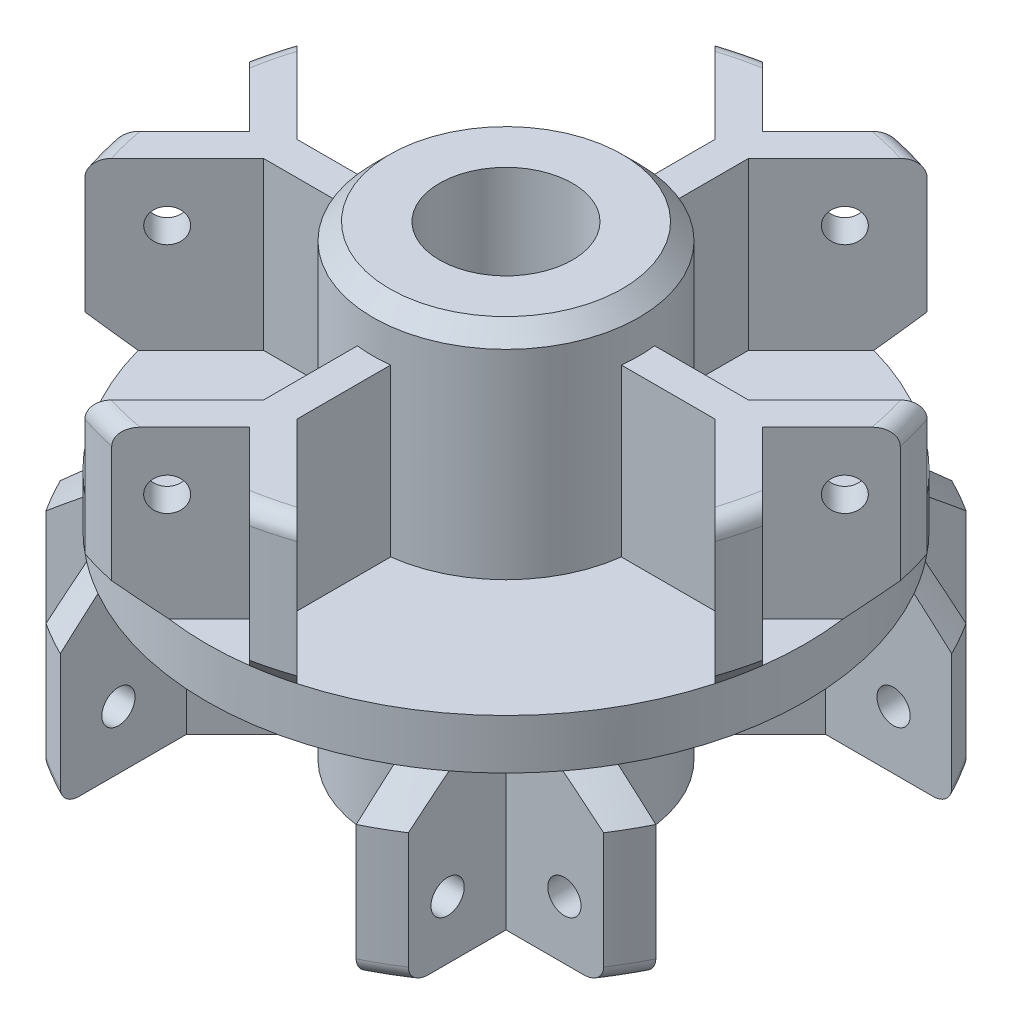
from build123d import *

# Parameters (mm, degrees)
SCHIZZO2_R                   = 20
ESTRUSIONE_ESTRUSIONE1_DEPTH = 14.5
SCHIZZO3_OUTSIDE_W           = 54.714
SCHIZZO3_OUTSIDE_H           = 54.714
SCHIZZO3_OUTSIDE_R           = 8
TAGLIO_ESTRUSIONE1_DEPTH     = 13
ESTRUSIONE_ESTRUSIONE2_DEPTH = 10
ESTRUSIONE_ESTRUSIONE3_DEPTH = 10
SMUSSO1_SIZE                 = 1
RACCORDO1_R                  = 1
SCHIZZO11_R                  = 4
TAGLIO_ESTRUSIONE2_DEPTH     = 30
FORO_2_0_2_1_D               = 2
RIPETIZIONECIRCOLARE1_COUNT  = 4
RIPETIZIONECIRCOLARE2_COUNT  = 4


with BuildPart() as part:
    # Schizzo2 → Estrusione-Estrusione1 (new body, symmetric)
    with BuildSketch(Plane(origin=(0, 0, 0), x_dir=(1, 0, 0), z_dir=(0, 1, 0))):
        Circle(SCHIZZO2_R)
    extrude(amount=ESTRUSIONE_ESTRUSIONE1_DEPTH, both=True)

    # Schizzo3 outside → Taglio-Estrusione1 (cut)
    with BuildSketch(Plane(origin=(0, 14.5, 0), x_dir=(1, 0, 0), z_dir=(0, 1, 0))):
        Rectangle(SCHIZZO3_OUTSIDE_W, SCHIZZO3_OUTSIDE_H)
        Circle(SCHIZZO3_OUTSIDE_R, mode=Mode.SUBTRACT)
    taglio_estrusione1 = extrude(amount=-TAGLIO_ESTRUSIONE1_DEPTH, mode=Mode.SUBTRACT)

    # Specchia2: Taglio-Estrusione1 across plane
    add(taglio_estrusione1.mirror(Plane.ZX), mode=Mode.SUBTRACT)

    # Schizzo6 → Estrusione-Estrusione2 (add)
    with BuildSketch(Plane(origin=(0, 1.5, 0), x_dir=(1, 0, 0), z_dir=(0, 1, 0))):
        with BuildLine():
            Line((1, 7.937253933), (1, 13.585786438))
            Line((1, 13.585786438), (6.371999001, 18.957785439))
            ThreePointArc((6.371999001, 18.957785439), (5.269942048, 19.293203747), (4.150401602, 19.564615165))
            Line((4.150401602, 19.564615165), (0, 15.414213562))
            Line((0, 15.414213562), (-4.150401602, 19.564615165))
            ThreePointArc((-4.150401602, 19.564615165), (-5.269942048, 19.293203747), (-6.371999001, 18.957785439))
            Line((-6.371999001, 18.957785439), (-1, 13.585786438))
            Line((-1, 13.585786438), (-1, 7.937253933))
            ThreePointArc((-1, 7.937253933), (0, 8), (1, 7.937253933))
        make_face()
        with BuildLine():
            Line((13.585786438, 1), (18.957785439, 6.371999001))
            ThreePointArc((18.957785439, 6.371999001), (19.293203747, 5.269942048), (19.564615165, 4.150401602))
            Line((19.564615165, 4.150401602), (15.414213562, 0))
            Line((15.414213562, 0), (19.564615165, -4.150401602))
            ThreePointArc((19.564615165, -4.150401602), (19.293203747, -5.269942048), (18.957785439, -6.371999001))
            Line((18.957785439, -6.371999001), (13.585786438, -1))
            Line((13.585786438, -1), (7.937253933, -1))
            ThreePointArc((7.937253933, -1), (8, 0), (7.937253933, 1))
            Line((7.937253933, 1), (13.585786438, 1))
        make_face()
        with BuildLine():
            Line((1, -13.585786438), (6.371999001, -18.957785439))
            ThreePointArc((6.371999001, -18.957785439), (5.269942048, -19.293203747), (4.150401602, -19.564615165))
            Line((4.150401602, -19.564615165), (0, -15.414213562))
            Line((0, -15.414213562), (-4.150401602, -19.564615165))
            ThreePointArc((-4.150401602, -19.564615165), (-5.269942048, -19.293203747), (-6.371999001, -18.957785439))
            Line((-6.371999001, -18.957785439), (-1, -13.585786438))
            Line((-1, -13.585786438), (-1, -7.937253933))
            ThreePointArc((-1, -7.937253933), (0, -8), (1, -7.937253933))
            Line((1, -7.937253933), (1, -13.585786438))
        make_face()
        with BuildLine():
            Line((-13.585786438, -1), (-18.957785439, -6.371999001))
            ThreePointArc((-18.957785439, -6.371999001), (-19.293203747, -5.269942048), (-19.564615165, -4.150401602))
            Line((-19.564615165, -4.150401602), (-15.414213562, 0))
            Line((-15.414213562, 0), (-19.564615165, 4.150401602))
            ThreePointArc((-19.564615165, 4.150401602), (-19.293203747, 5.269942048), (-18.957785439, 6.371999001))
            Line((-18.957785439, 6.371999001), (-13.585786438, 1))
            Line((-13.585786438, 1), (-7.937253933, 1))
            ThreePointArc((-7.937253933, 1), (-8, 0), (-7.937253933, -1))
            Line((-7.937253933, -1), (-13.585786438, -1))
        make_face()
    extrude(amount=ESTRUSIONE_ESTRUSIONE2_DEPTH)

    # Schizzo20 → Estrusione-Estrusione3 (add)
    with BuildSketch(Plane(origin=(0, -1.5, 0), x_dir=(-1, 0, 0), z_dir=(0, -1, 0))):
        with BuildLine():
            Line((4.905379299, -6.319592861), (8.899494937, -10.313708499))
            Line((8.899494937, -10.313708499), (8.899494937, -17.910862343))
            ThreePointArc((8.899494937, -17.910862343), (9.915943441, -17.368766959), (10.899494937, -16.769049172))
            Line((10.899494937, -16.769049172), (10.899494937, -10.899494937))
            Line((10.899494937, -10.899494937), (16.769049172, -10.899494937))
            ThreePointArc((16.769049172, -10.899494937), (17.368766959, -9.915943441), (17.910862343, -8.899494937))
            Line((17.910862343, -8.899494937), (10.313708499, -8.899494937))
            Line((10.313708499, -8.899494937), (6.319592861, -4.905379299))
            ThreePointArc((6.319592861, -4.905379299), (5.656854249, -5.656854249), (4.905379299, -6.319592861))
        make_face()
        with BuildLine():
            Line((-4.905379299, -6.319592861), (-8.899494937, -10.313708499))
            Line((-8.899494937, -10.313708499), (-8.899494937, -17.910862343))
            ThreePointArc((-8.899494937, -17.910862343), (-9.915943441, -17.368766959), (-10.899494937, -16.769049172))
            Line((-10.899494937, -16.769049172), (-10.899494937, -10.899494937))
            Line((-10.899494937, -10.899494937), (-16.769049172, -10.899494937))
            ThreePointArc((-16.769049172, -10.899494937), (-17.368766959, -9.915943441), (-17.910862343, -8.899494937))
            Line((-17.910862343, -8.899494937), (-10.313708499, -8.899494937))
            Line((-10.313708499, -8.899494937), (-6.319592861, -4.905379299))
            ThreePointArc((-6.319592861, -4.905379299), (-5.656854249, -5.656854249), (-4.905379299, -6.319592861))
        make_face()
        with BuildLine():
            Line((-6.319592861, 4.905379299), (-10.313708499, 8.899494937))
            Line((-10.313708499, 8.899494937), (-17.910862343, 8.899494937))
            ThreePointArc((-17.910862343, 8.899494937), (-17.368766959, 9.915943441), (-16.769049172, 10.899494937))
            Line((-16.769049172, 10.899494937), (-10.899494937, 10.899494937))
            Line((-10.899494937, 10.899494937), (-10.899494937, 16.769049172))
            ThreePointArc((-10.899494937, 16.769049172), (-9.915943441, 17.368766959), (-8.899494937, 17.910862343))
            Line((-8.899494937, 17.910862343), (-8.899494937, 10.313708499))
            Line((-8.899494937, 10.313708499), (-4.905379299, 6.319592861))
            ThreePointArc((-4.905379299, 6.319592861), (-5.656854249, 5.656854249), (-6.319592861, 4.905379299))
        make_face()
        with BuildLine():
            Line((4.905379299, 6.319592861), (8.899494937, 10.313708499))
            Line((8.899494937, 10.313708499), (8.899494937, 17.910862343))
            ThreePointArc((8.899494937, 17.910862343), (9.915943441, 17.368766959), (10.899494937, 16.769049172))
            Line((10.899494937, 16.769049172), (10.899494937, 10.899494937))
            Line((10.899494937, 10.899494937), (16.769049172, 10.899494937))
            ThreePointArc((16.769049172, 10.899494937), (17.368766959, 9.915943441), (17.910862343, 8.899494937))
            Line((17.910862343, 8.899494937), (10.313708499, 8.899494937))
            Line((10.313708499, 8.899494937), (6.319592861, 4.905379299))
            ThreePointArc((6.319592861, 4.905379299), (5.656854249, 5.656854249), (4.905379299, 6.319592861))
        make_face()
    extrude(amount=ESTRUSIONE_ESTRUSIONE3_DEPTH)

    # Smusso1
    smusso1_edges = [part.edges().sort_by_distance(p)[0] for p in [
        (-8, 14.5, 0),
        (-8, -14.5, 0),
    ]]
    chamfer(smusso1_edges, length=SMUSSO1_SIZE)

    # Raccordo1
    raccordo1_edges = [part.edges().sort_by_distance(p)[0] for p in [
        (-19.293203747, 11.5, 5.269942048),
        (-19.293203747, 11.5, -5.269942048),
        (-17.368766959, -11.5, 9.915943441),
        (-9.915943441, -11.5, 17.368766959),
        (9.915943441, -11.5, 17.368766959),
        (17.368766959, -11.5, 9.915943441),
        (17.368766959, -11.5, -9.915943441),
        (9.915943441, -11.5, -17.368766959),
        (-9.915943441, -11.5, -17.368766959),
        (-17.368766959, -11.5, -9.915943441),
        (-5.269942048, 11.5, -19.293203747),
        (5.269942048, 11.5, -19.293203747),
        (19.293203747, 11.5, -5.269942048),
        (19.293203747, 11.5, 5.269942048),
        (5.269942048, 11.5, 19.293203747),
        (-5.269942048, 11.5, 19.293203747),
    ]]
    fillet(raccordo1_edges, radius=RACCORDO1_R)

    # Schizzo11 → Taglio-Estrusione2 (cut, through all)
    with BuildSketch(Plane(origin=(0, 14.5, 0), x_dir=(1, 0, 0), z_dir=(0, 1, 0))):
        Circle(SCHIZZO11_R)
    extrude(amount=-TAGLIO_ESTRUSIONE2_DEPTH, mode=Mode.SUBTRACT)

    # Schizzo22 → Taglia-Rivoluzione1 (revolve, cut)
    with BuildSketch(Plane(origin=(0, 0, 0), x_dir=(0, 0, -1), z_dir=(1, 0, 0))):
        Polygon((-18, 1.5), (-20, 3.5), (-20, 1.5), (-20, -1.5), (-20, -3.5), (-18, -1.5), align=None)
    revolve(axis=Axis((0, -14.5, 0), (0, 1, 0)), mode=Mode.SUBTRACT)

    # Foro Ø2.0 (2)-1 (through all)
    with Locations(Plane(origin=(7.707106781, 0, 7.707106781), x_dir=(0.707106781, 0, -0.707106781), z_dir=(0.707106781, 0, 0.707106781))):
        with Locations((-14.410862343, 8)):
            foro_2_0_2_1 = Hole(FORO_2_0_2_1_D / 2)

    # RipetizioneCircolare1: Foro Ø2.0 (2)-1 ×4 about axis
    ripetizionecircolare1_axis = Axis((0, -14.5, 0), (0, 1, 0))
    for i in range(1, RIPETIZIONECIRCOLARE1_COUNT):
        add(foro_2_0_2_1.rotate(ripetizionecircolare1_axis, i * 360 / RIPETIZIONECIRCOLARE1_COUNT), mode=Mode.SUBTRACT)

    # Schizzo25 → Foro Ø2.0 (2)-2 (revolve, cut)
    with BuildSketch(Plane(origin=(10.899494937, -8, 14.410862343), x_dir=(0, 0, -1), z_dir=(0, 1, 0))):
        Polygon((0, 0), (0, 39.300860619), (1, 38.7), (1, 0), align=None)
    foro_2_0_2_2 = revolve(axis=Axis((17.249494937, -8, 14.410862343), (-1, 0, 0)), mode=Mode.SUBTRACT)

    # RipetizioneCircolare2: Foro Ø2.0 (2)-2 ×4 about axis
    ripetizionecircolare2_axis = Axis((0, -14.5, 0), (0, 1, 0))
    for i in range(1, RIPETIZIONECIRCOLARE2_COUNT):
        add(foro_2_0_2_2.rotate(ripetizionecircolare2_axis, i * 360 / RIPETIZIONECIRCOLARE2_COUNT), mode=Mode.SUBTRACT)


solid = part.part
